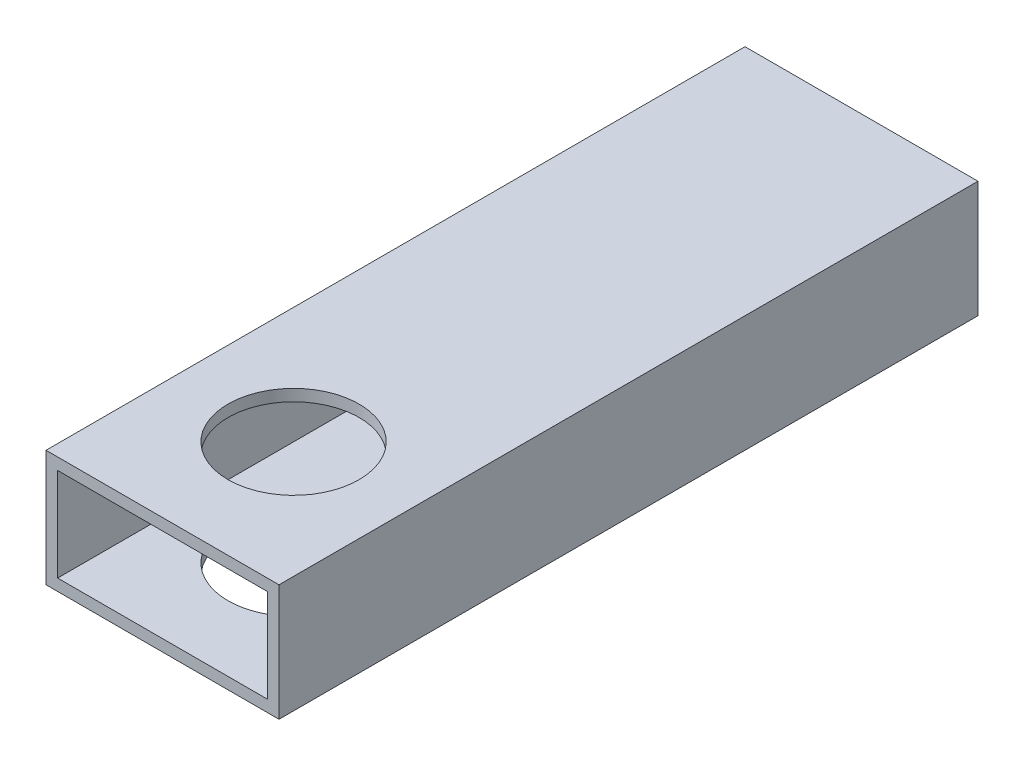
from build123d import *

# Parameters (mm, degrees)
SKETCH1_W           = 50.8
SKETCH1_H           = 25.4
SKETCH1_W_2         = 45.72
SKETCH1_H_2         = 20.32
BOSS_EXTRUDE1_DEPTH = 152.4
SKETCH2_R           = 14.2875
CUT_EXTRUDE1_DEPTH  = 152.4


with BuildPart() as part:
    # Sketch1 → Boss-Extrude1 (new body)
    with BuildSketch(Plane.XY):
        with Locations((25.4, -12.7)):
            Rectangle(SKETCH1_W, SKETCH1_H)
        with Locations((25.4, -12.7)):
            Rectangle(SKETCH1_W_2, SKETCH1_H_2, mode=Mode.SUBTRACT)
    extrude(amount=BOSS_EXTRUDE1_DEPTH)

    # Sketch2 → Cut-Extrude1 (cut)
    with BuildSketch(Plane(origin=(0, 0, 0), x_dir=(1, 0, 0), z_dir=(0, 1, 0))):
        with Locations((25.4, -123.825)):
            Circle(SKETCH2_R)
    extrude(amount=-CUT_EXTRUDE1_DEPTH, mode=Mode.SUBTRACT)


solid = part.part
